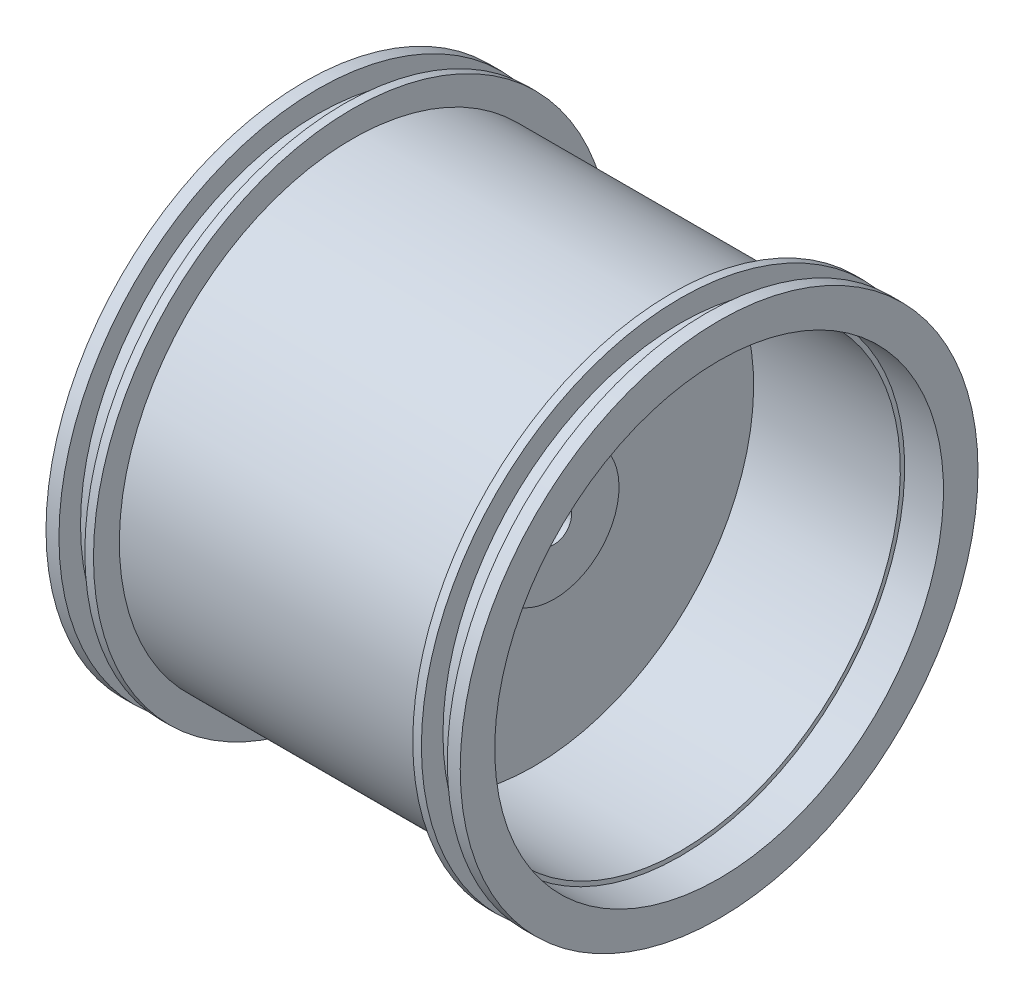
from build123d import *

# Parameters (mm, degrees)
CORTAR_EXTRUIR1_REACH   = 53.334
CROQUIS2_R              = 2
CROQUIS3_R              = 2
SALIENTE_EXTRUIR1_DEPTH = 6.6
CORTAR_EXTRUIR2_DEPTH   = 4.2


with BuildPart() as part:
    # Croquis1 → Revolución1 (revolve)
    with BuildSketch(Plane.XY, mode=Mode.PRIVATE) as revoluci_n1_sk:
        Polygon((-2.5, 7.5), (-2.5, 0), (4.9, 0), (4.9, 7.5), (2.5, 7.5), (2.5, 25.5), (19.5, 25.5), (19.5, 26), (24, 26), (24, 30), (22.5, 30), (22.5, 27.5), (19.5, 27.5), (19.5, 30), (18.5, 30), (18.5, 27), (-18.5, 27), (-18.5, 30), (-19.5, 30), (-19.5, 27.5), (-22.5, 27.5), (-22.5, 30), (-24, 30), (-24, 26), (-19.5, 26), (-19.5, 25.5), (-2.5, 25.5), align=None)
    revolve(revoluci_n1_sk.sketch.rotate(Axis((-2.5, 0, 0), (1, 0, 0)), 180), axis=Axis((-2.5, 0, 0), (1, 0, 0)))

    # Croquis2 → Cortar-Extruir1 (cut, up to next)
    with BuildSketch(Plane(origin=(4.9, 0, 0), x_dir=(0, 0, -1), z_dir=(1, 0, 0)), mode=Mode.PRIVATE) as cortar_extruir1_sk1:
        with Locations(Location((0, 0, 0), (0, 0, 90))):
            Circle(CROQUIS2_R)
    cortar_extruir1_tool1 = extrude(cortar_extruir1_sk1.sketch, amount=-CORTAR_EXTRUIR1_REACH, mode=Mode.PRIVATE) & part.part
    add(cortar_extruir1_tool1.solids().sort_by_distance((4.9, 0, 0))[0], mode=Mode.SUBTRACT)

    # Croquis3 → Saliente-Extruir1 (add)
    with BuildSketch(Plane.ZY.offset(2.5)):
        Polygon((0, 8.256108849), (-7.15, 4.128054425), (-7.15, -4.128054425), (0, -8.256108849), (7.15, -4.128054425), (7.15, 4.128054425), align=None)
        with Locations(Location((0, 0, 0), (0, 0, 90))):
            Circle(CROQUIS3_R, mode=Mode.SUBTRACT)
    extrude(amount=SALIENTE_EXTRUIR1_DEPTH)

    # Croquis4 → Cortar-Extruir2 (cut)
    with BuildSketch(Plane.ZY.offset(9.1)):
        Polygon((6.15, 3.550704156), (0, 7.101408311), (-6.15, 3.550704156), (-6.15, -3.550704156), (0, -7.101408311), (6.15, -3.550704156), align=None)
    extrude(amount=-CORTAR_EXTRUIR2_DEPTH, mode=Mode.SUBTRACT)


solid = part.part
